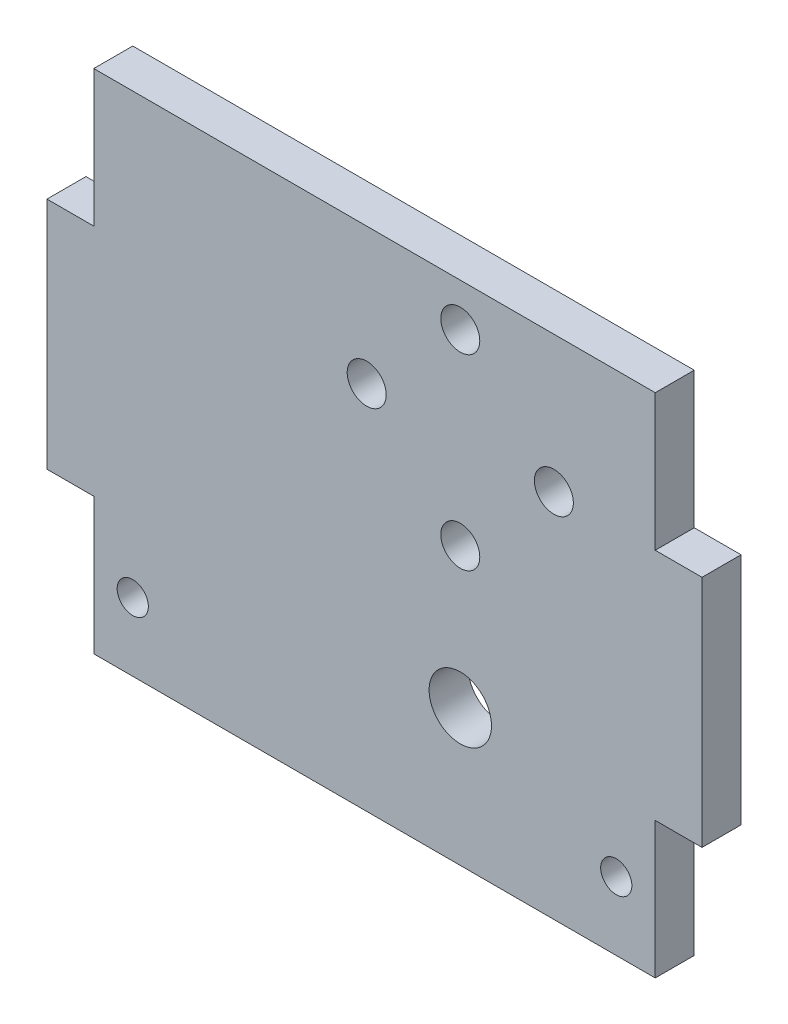
from build123d import *

# Parameters (mm, degrees)
SKETCH2_W           = 50
SKETCH2_H           = 65
SKETCH2_R           = 2
SKETCH2_R_2         = 4
BOSS_EXTRUDE1_DEPTH = 5
SKETCH3_W           = 21
SKETCH3_H           = 65
BOSS_EXTRUDE2_DEPTH = 5
SKETCH4_W           = 1
SKETCH4_H           = 65
BOSS_EXTRUDE3_DEPTH = 5
BOSS_EXTRUDE4_DEPTH = 5
SKETCH6_R           = 2
CUT_EXTRUDE1_DEPTH  = 59
SKETCH7_R           = 1.5
CUT_EXTRUDE2_DEPTH  = 10
SKETCH7_4_R         = 1.5
CUT_EXTRUDE3_DEPTH  = 10
SKETCH7_5_R         = 1.5
BOSS_EXTRUDE5_DEPTH = 5
SKETCH8_R           = 2
CUT_EXTRUDE4_DEPTH  = 10
SKETCH9_R           = 2.5
CUT_EXTRUDE5_DEPTH  = 10


with BuildPart() as part:
    # Sketch2 → Boss-Extrude1 (new body)
    with BuildSketch(Plane.XY):
        with Locations((25, 32.5)):
            Rectangle(SKETCH2_W, SKETCH2_H)
        with Locations((25, 59.5)):
            Circle(SKETCH2_R, mode=Mode.SUBTRACT)
        with Locations((13, 47.5)):
            Circle(SKETCH2_R, mode=Mode.SUBTRACT)
        with Locations((37, 47.5)):
            Circle(SKETCH2_R, mode=Mode.SUBTRACT)
        with Locations((25, 17.5)):
            Circle(SKETCH2_R_2, mode=Mode.SUBTRACT)
    extrude(amount=BOSS_EXTRUDE1_DEPTH)

    # Sketch3 → Boss-Extrude2 (add)
    with BuildSketch(Plane.XY.offset(5)):
        with Locations((-10.5, 32.5)):
            Rectangle(SKETCH3_W, SKETCH3_H)
    extrude(amount=-BOSS_EXTRUDE2_DEPTH)

    # Sketch4 → Boss-Extrude3 (add)
    with BuildSketch(Plane.XY.offset(5)):
        with Locations((-21.5, 32.5)):
            Rectangle(SKETCH4_W, SKETCH4_H)
    extrude(amount=-BOSS_EXTRUDE3_DEPTH)

    # Sketch5 → Boss-Extrude4 (add)
    with BuildSketch(Plane.XY.offset(5)):
        Polygon((-22, 17.5), (-22, 32.5), (-22, 47.5), (-28, 47.5), (-28, 17.5), align=None)
        Polygon((56, 17.5), (56, 47.5), (50, 47.5), (50, 32.5), (50, 17.5), align=None)
    extrude(amount=-BOSS_EXTRUDE4_DEPTH)

    # Sketch6 → Cut-Extrude1 (cut)
    with BuildSketch(Plane.XY.offset(5)):
        with Locations((25, 35.5)):
            Circle(SKETCH6_R)
    extrude(amount=-CUT_EXTRUDE1_DEPTH, mode=Mode.SUBTRACT)

    # Sketch7 → Cut-Extrude2 (cut)
    with BuildSketch(Plane.XY.offset(5)):
        with Locations((-17, 56.25)):
            Circle(SKETCH7_R)
        with Locations((45, 56.25)):
            Circle(SKETCH7_R)
    extrude(amount=-CUT_EXTRUDE2_DEPTH, mode=Mode.SUBTRACT)

    # Sketch7_4 → Cut-Extrude3 (cut)
    with BuildSketch(Plane.XY.offset(5)):
        with Locations((45, 8.75)):
            Circle(SKETCH7_4_R)
        with Locations((-17, 8.75)):
            Circle(SKETCH7_4_R)
    extrude(amount=-CUT_EXTRUDE3_DEPTH, mode=Mode.SUBTRACT)

    # Sketch7_5 → Boss-Extrude5 (add)
    with BuildSketch(Plane.XY.offset(5)):
        with Locations((-17, 56.25)):
            Circle(SKETCH7_5_R)
        with Locations((45, 56.25)):
            Circle(SKETCH7_5_R)
    extrude(amount=-BOSS_EXTRUDE5_DEPTH)

    # Sketch8 → Cut-Extrude4 (cut)
    with BuildSketch(Plane.XY.offset(5)):
        with Locations((-17, 8.75)):
            Circle(SKETCH8_R)
        with Locations((45, 8.75)):
            Circle(SKETCH8_R)
    extrude(amount=-CUT_EXTRUDE4_DEPTH, mode=Mode.SUBTRACT)

    # Sketch9 → Cut-Extrude5 (cut)
    with BuildSketch(Plane.XY.offset(5)):
        with Locations((25, 59.5)):
            Circle(SKETCH9_R)
        with Locations((25, 35.5)):
            Circle(SKETCH9_R)
        with Locations((13, 47.5)):
            Circle(SKETCH9_R)
        with Locations((37, 47.5)):
            Circle(SKETCH9_R)
    extrude(amount=-CUT_EXTRUDE5_DEPTH, mode=Mode.SUBTRACT)


solid = part.part
